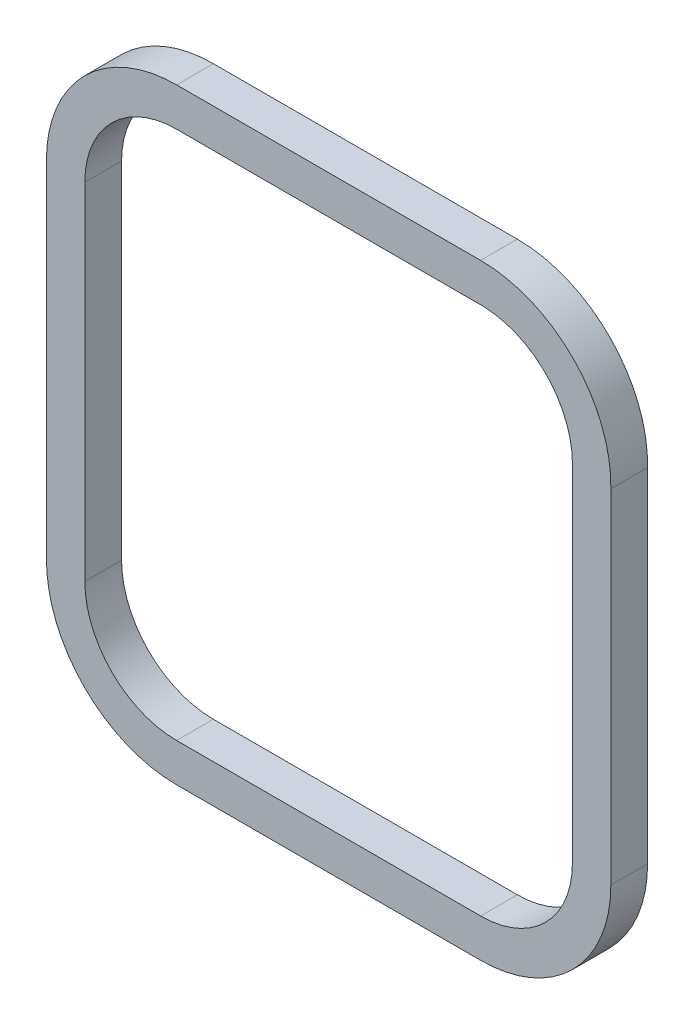
from build123d import *

# Parameters (mm, degrees)
BOSS_EXTRUDE1_DEPTH = 2.2


with BuildPart() as part:
    # Sketch1 → Boss-Extrude1 (new body)
    with BuildSketch(Plane.XY):
        with BuildLine():
            Line((-18.150001357, 10.34999793), (-18.150001357, -10.350000028))
            ThreePointArc((-18.150001357, -10.350000028), (-15.865433985, -15.865433561), (-10.350000452, -18.150000933))
            Line((-10.350000452, -18.150000933), (7.849999548, -18.150000933))
            ThreePointArc((7.849999548, -18.150000933), (13.365432561, -15.865433706), (15.649999548, -10.350000592))
            Line((15.649999548, -10.350000592), (15.649998649, 10.202018436))
            ThreePointArc((15.649998649, 10.202018436), (13.418409956, 15.813346519), (7.849998643, 18.149965101))
            Line((7.849998643, 18.149965101), (-10.349987141, 18.149998271))
            ThreePointArc((-10.349987141, 18.149998271), (-15.865429345, 15.86543607), (-18.150001357, 10.34999793))
        make_face()
        with BuildLine():
            Line((-15.850000452, 10.349999067), (-15.850000452, -10.350000028))
            ThreePointArc((-15.850000452, -10.350000028), (-14.239087554, -14.239087795), (-10.349999788, -15.850000693))
            Line((-10.349999788, -15.850000693), (7.849999548, -15.850000693))
            ThreePointArc((7.849999548, -15.850000693), (11.739086259, -14.239087669), (13.349998643, -10.350000693))
            Line((13.349998643, -10.350000693), (13.349998643, 10.349999307))
            ThreePointArc((13.349998643, 10.349999307), (11.810252303, 14.16659361), (8.05312906, 15.846247087))
            Line((8.05312906, 15.846247087), (-10.348878781, 15.849999193))
            ThreePointArc((-10.348878781, 15.849999193), (-14.238691173, 14.239482999), (-15.850000452, 10.349999067))
        make_face(mode=Mode.SUBTRACT)
    extrude(amount=BOSS_EXTRUDE1_DEPTH)


solid = part.part
